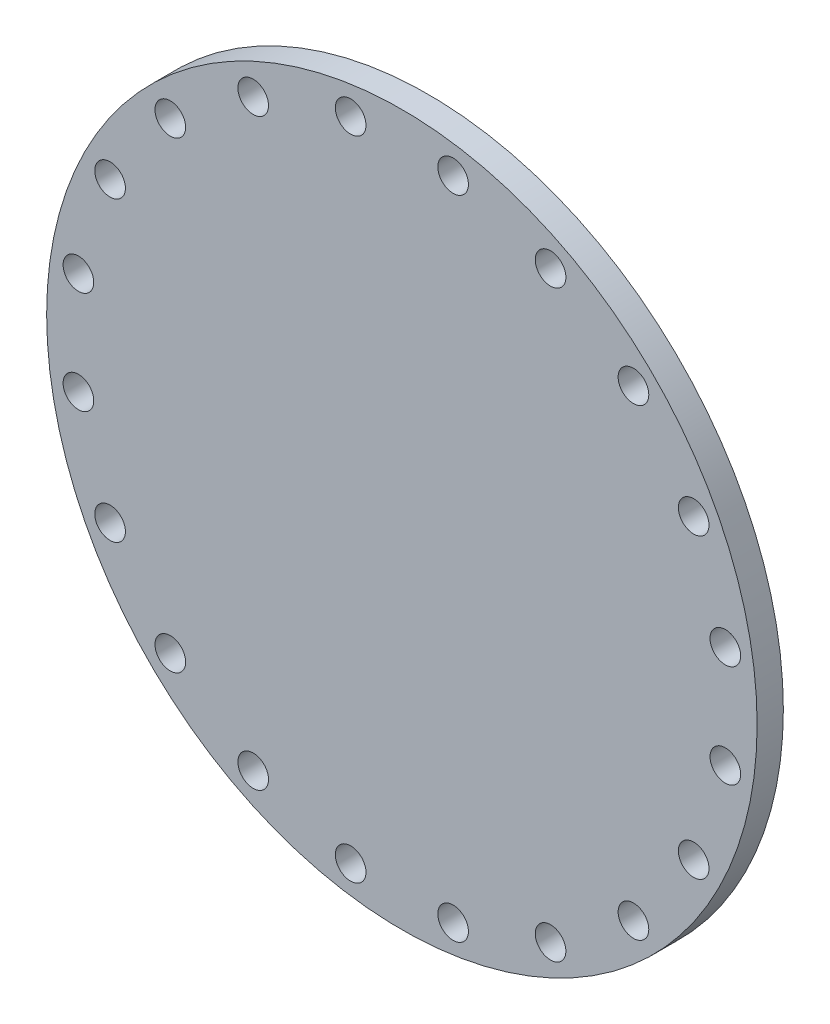
from build123d import *

# Parameters (mm, degrees)
SKETCH1_R          = 406.4
EXTRUDE1_DEPTH     = 30
SKETCH2_R          = 17.526
CUT_EXTRUDE1_DEPTH = 31
CIRPATTERN1_COUNT  = 20


with BuildPart() as part:
    # Sketch1 → Extrude1 (new body)
    with BuildSketch(Plane.XY):
        Circle(SKETCH1_R)
    extrude(amount=EXTRUDE1_DEPTH)

    # Sketch2 → Cut-Extrude1 (cut, through all)
    with BuildSketch(Plane(origin=(0, 0, 0), x_dir=(-1, 0, 0), z_dir=(0, 0, -1))):
        with Locations((58.608172327, 370.037436804)):
            Circle(SKETCH2_R)
    cut_extrude1 = extrude(amount=-CUT_EXTRUDE1_DEPTH, mode=Mode.SUBTRACT)

    # CirPattern1: Cut-Extrude1 ×20 about axis
    cirpattern1_axis = Axis((0, 0, 0), (0, 0, 1))
    for i in range(1, CIRPATTERN1_COUNT):
        add(cut_extrude1.rotate(cirpattern1_axis, i * 360 / CIRPATTERN1_COUNT), mode=Mode.SUBTRACT)


solid = part.part
